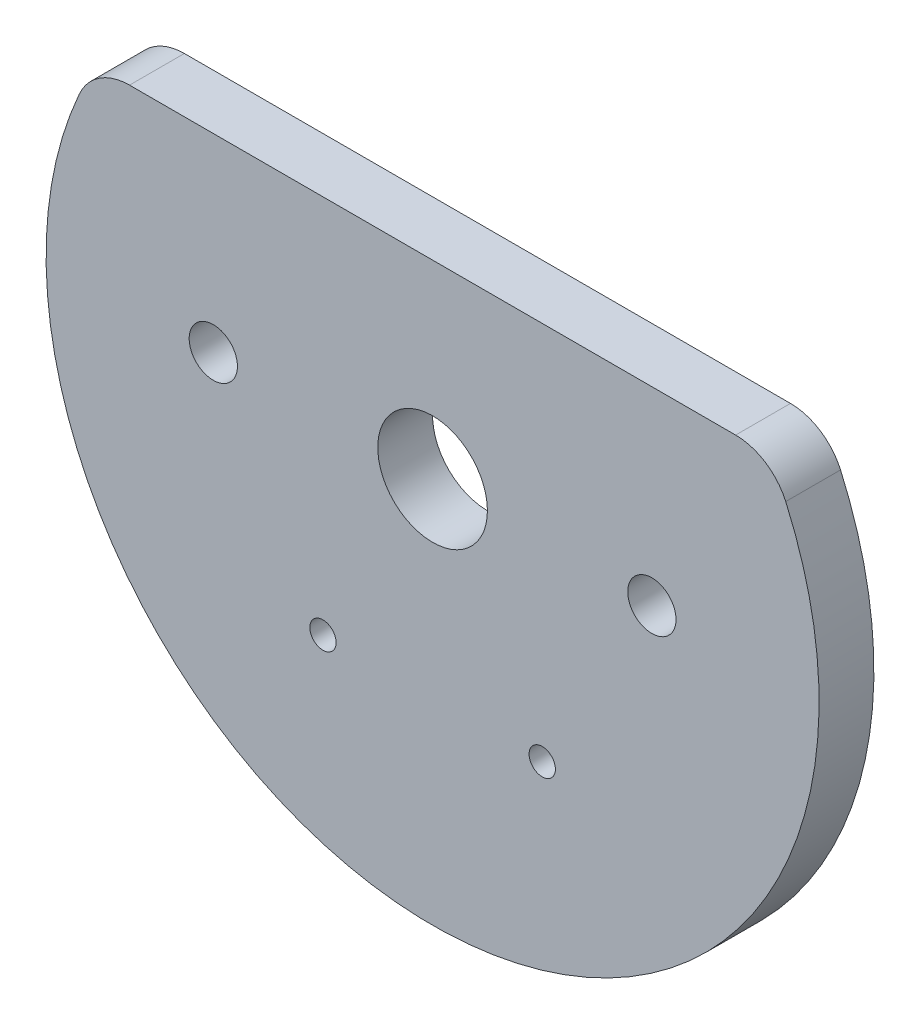
from build123d import *

# Parameters (mm, degrees)
SKETCH1_R           = 22.38375
BOSS_EXTRUDE1_DEPTH = 3.175
CUT_EXTRUDE1_REACH  = 5.175
SKETCH2_R           = 38.03700281
CUT_EXTRUDE3_REACH  = 5.175
SKETCH4_R           = 1.397
SKETCH4_R_2         = 0.762
BOSS_EXTRUDE2_DEPTH = 3.175
CUT_EXTRUDE4_REACH  = 5.175
SKETCH8_R           = 3.175


with BuildPart() as part:
    # Sketch1 → Boss-Extrude1 (new body)
    with BuildSketch(Plane.XY):
        with Locations((69.054102373, -28.60314574)):
            Circle(SKETCH1_R)
    extrude(amount=BOSS_EXTRUDE1_DEPTH)

    # Sketch2 → Cut-Extrude1 (cut, up to next)
    with BuildSketch(Plane.XY.offset(3.175), mode=Mode.PRIVATE) as cut_extrude1_sk1:
        with Locations((69.054102373, 12.564876285)):
            Circle(SKETCH2_R)
    cut_extrude1_tool1 = extrude(cut_extrude1_sk1.sketch, amount=-CUT_EXTRUDE1_REACH, mode=Mode.PRIVATE) & part.part
    add(cut_extrude1_tool1.solids().sort_by_distance((69.054102, 12.564876, 3.175))[0], mode=Mode.SUBTRACT)

    # Sketch4 → Cut-Extrude3 (cut, up to next)
    with BuildSketch(Plane.XY.offset(3.175), mode=Mode.PRIVATE) as cut_extrude3_sk1:
        with Locations((56.354102373, -28.60314574)):
            Circle(SKETCH4_R)
    cut_extrude3_tool1 = extrude(cut_extrude3_sk1.sketch, amount=-CUT_EXTRUDE3_REACH, mode=Mode.PRIVATE) & part.part
    add(cut_extrude3_tool1.solids().sort_by_distance((56.354102, -28.603146, 3.175))[0], mode=Mode.SUBTRACT)
    # Sketch4 → Cut-Extrude3 (cut, up to next)
    with BuildSketch(Plane.XY.offset(3.175), mode=Mode.PRIVATE) as cut_extrude3_sk2:
        with Locations((81.754102373, -28.60314574)):
            Circle(SKETCH4_R)
    cut_extrude3_tool2 = extrude(cut_extrude3_sk2.sketch, amount=-CUT_EXTRUDE3_REACH, mode=Mode.PRIVATE) & part.part
    add(cut_extrude3_tool2.solids().sort_by_distance((81.754102, -28.603146, 3.175))[0], mode=Mode.SUBTRACT)
    # Sketch4 → Cut-Extrude3 (cut, up to next)
    with BuildSketch(Plane.XY.offset(3.175), mode=Mode.PRIVATE) as cut_extrude3_sk3:
        with Locations((62.704102373, -39.601668368)):
            Circle(SKETCH4_R_2)
    cut_extrude3_tool3 = extrude(cut_extrude3_sk3.sketch, amount=-CUT_EXTRUDE3_REACH, mode=Mode.PRIVATE) & part.part
    add(cut_extrude3_tool3.solids().sort_by_distance((62.704102, -39.601668, 3.175))[0], mode=Mode.SUBTRACT)
    # Sketch4 → Cut-Extrude3 (cut, up to next)
    with BuildSketch(Plane.XY.offset(3.175), mode=Mode.PRIVATE) as cut_extrude3_sk4:
        with Locations((75.404102373, -39.601668368)):
            Circle(SKETCH4_R_2)
    cut_extrude3_tool4 = extrude(cut_extrude3_sk4.sketch, amount=-CUT_EXTRUDE3_REACH, mode=Mode.PRIVATE) & part.part
    add(cut_extrude3_tool4.solids().sort_by_distance((75.404102, -39.601668, 3.175))[0], mode=Mode.SUBTRACT)

    # Sketch7 → Boss-Extrude2 (add)
    with BuildSketch(Plane.XY.offset(3.175)):
        with BuildLine():
            Line((51.503315193, -17.621357289), (86.604889553, -17.621357289))
            ThreePointArc((86.604889553, -17.621357289), (88.334582305, -18.133879499), (89.505846111, -19.505979033))
            ThreePointArc((89.505846111, -19.505979033), (69.054102373, -25.472126525), (48.602358634, -19.505979033))
            ThreePointArc((48.602358634, -19.505979033), (49.77362244, -18.133879499), (51.503315193, -17.621357289))
        make_face()
    extrude(amount=-BOSS_EXTRUDE2_DEPTH)

    # Sketch8 → Cut-Extrude4 (cut, up to next)
    with BuildSketch(Plane.XY.offset(3.175), mode=Mode.PRIVATE) as cut_extrude4_sk1:
        with Locations((69.054102373, -28.60314574)):
            Circle(SKETCH8_R)
    cut_extrude4_tool1 = extrude(cut_extrude4_sk1.sketch, amount=-CUT_EXTRUDE4_REACH, mode=Mode.PRIVATE) & part.part
    add(cut_extrude4_tool1.solids().sort_by_distance((69.054102, -28.603146, 3.175))[0], mode=Mode.SUBTRACT)


solid = part.part
